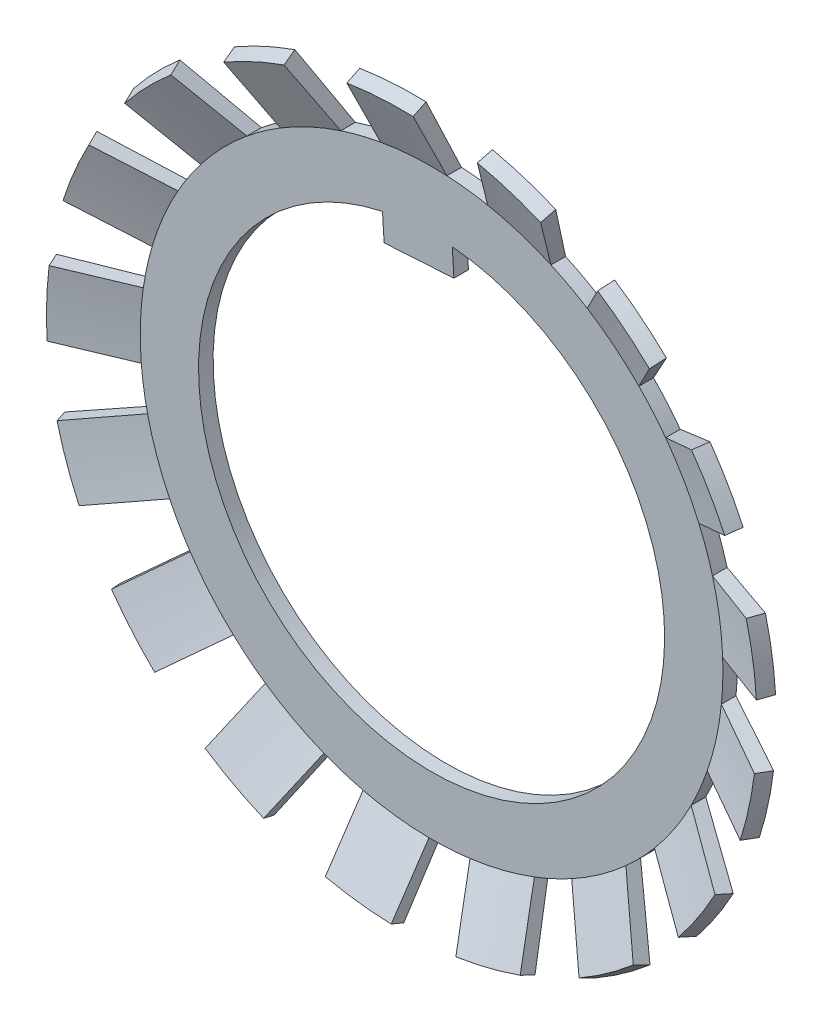
from build123d import *

# Parameters (mm, degrees)
SKETCH2_OUTSIDE_W        = 81.552
SKETCH2_OUTSIDE_H        = 81.552
SKETCH2_OUTSIDE_R        = 20
CUT_EXTRUDE_DEPTH        = 4.810952862
PATTERN_CIRCULAR_4_COUNT = 17
EXTRUDE_1_DEPTH          = 1.25


with BuildPart() as part:
    # Sketch1 → Base-Extrude (revolve)
    with BuildSketch(Plane.YZ):
        Polygon((0, -3.810952863), (-25, -3.810952863), (-31, -1.142110693), (-30.491981137, 0), (-25, -2.560952863), (0, -2.560952863), align=None)
    revolve(axis=Axis((0, 0, 5.823648763), (0, 0, -1)))

    # Sketch2 outside → Cut-Extrude (cut, through all)
    with BuildSketch(Plane(origin=(-2.40435344, 1.003568156, -3.810952862), x_dir=(-1, 0, 0), z_dir=(0, 0, -1))):
        with Locations((-2.404, -1.004)):
            Rectangle(SKETCH2_OUTSIDE_W, SKETCH2_OUTSIDE_H)
        with BuildLine():
            Line((-22.488842625, 13.883113616), (-27.712443889, 16.898961212))
            ThreePointArc((-27.712443889, 16.898961212), (-29.251140957, 14.496431844), (-30.562443889, 11.96261641))
            Line((-30.562443889, 11.96261641), (-25.338842625, 8.946768814))
            ThreePointArc((-25.338842625, 8.946768814), (19.246281655, -13.503568156), (-22.488842625, 13.883113616))
        make_face(mode=Mode.SUBTRACT)
        with Locations((-2.40435344, -1.003568156)):
            Circle(SKETCH2_OUTSIDE_R)
    extrude(amount=-CUT_EXTRUDE_DEPTH, mode=Mode.SUBTRACT)


with BuildPart() as pattern_circular_4_1:
    # 阵列(圆周)4: pattern copy
    add(part.part.rotate(Axis((0, 0, 0), (0, 0, 1)), 1 * 360 / PATTERN_CIRCULAR_4_COUNT))


with BuildPart() as pattern_circular_4_2:
    # 阵列(圆周)4: pattern copy
    add(part.part.rotate(Axis((0, 0, 0), (0, 0, 1)), 2 * 360 / PATTERN_CIRCULAR_4_COUNT))


with BuildPart() as pattern_circular_4_3:
    # 阵列(圆周)4: pattern copy
    add(part.part.rotate(Axis((0, 0, 0), (0, 0, 1)), 3 * 360 / PATTERN_CIRCULAR_4_COUNT))


with BuildPart() as pattern_circular_4_4:
    # 阵列(圆周)4: pattern copy
    add(part.part.rotate(Axis((0, 0, 0), (0, 0, 1)), 4 * 360 / PATTERN_CIRCULAR_4_COUNT))


with BuildPart() as pattern_circular_4_5:
    # 阵列(圆周)4: pattern copy
    add(part.part.rotate(Axis((0, 0, 0), (0, 0, 1)), 5 * 360 / PATTERN_CIRCULAR_4_COUNT))


with BuildPart() as pattern_circular_4_6:
    # 阵列(圆周)4: pattern copy
    add(part.part.rotate(Axis((0, 0, 0), (0, 0, 1)), 6 * 360 / PATTERN_CIRCULAR_4_COUNT))


with BuildPart() as pattern_circular_4_7:
    # 阵列(圆周)4: pattern copy
    add(part.part.rotate(Axis((0, 0, 0), (0, 0, 1)), 7 * 360 / PATTERN_CIRCULAR_4_COUNT))


with BuildPart() as pattern_circular_4_8:
    # 阵列(圆周)4: pattern copy
    add(part.part.rotate(Axis((0, 0, 0), (0, 0, 1)), 8 * 360 / PATTERN_CIRCULAR_4_COUNT))


with BuildPart() as pattern_circular_4_9:
    # 阵列(圆周)4: pattern copy
    add(part.part.rotate(Axis((0, 0, 0), (0, 0, 1)), 9 * 360 / PATTERN_CIRCULAR_4_COUNT))


with BuildPart() as pattern_circular_4_10:
    # 阵列(圆周)4: pattern copy
    add(part.part.rotate(Axis((0, 0, 0), (0, 0, 1)), 10 * 360 / PATTERN_CIRCULAR_4_COUNT))


with BuildPart() as pattern_circular_4_11:
    # 阵列(圆周)4: pattern copy
    add(part.part.rotate(Axis((0, 0, 0), (0, 0, 1)), 11 * 360 / PATTERN_CIRCULAR_4_COUNT))


with BuildPart() as pattern_circular_4_12:
    # 阵列(圆周)4: pattern copy
    add(part.part.rotate(Axis((0, 0, 0), (0, 0, 1)), 12 * 360 / PATTERN_CIRCULAR_4_COUNT))


with BuildPart() as pattern_circular_4_13:
    # 阵列(圆周)4: pattern copy
    add(part.part.rotate(Axis((0, 0, 0), (0, 0, 1)), 13 * 360 / PATTERN_CIRCULAR_4_COUNT))


with BuildPart() as pattern_circular_4_14:
    # 阵列(圆周)4: pattern copy
    add(part.part.rotate(Axis((0, 0, 0), (0, 0, 1)), 14 * 360 / PATTERN_CIRCULAR_4_COUNT))


with BuildPart() as pattern_circular_4_15:
    # 阵列(圆周)4: pattern copy
    add(part.part.rotate(Axis((0, 0, 0), (0, 0, 1)), 15 * 360 / PATTERN_CIRCULAR_4_COUNT))


with BuildPart() as pattern_circular_4_16:
    # 阵列(圆周)4: pattern copy
    add(part.part.rotate(Axis((0, 0, 0), (0, 0, 1)), 16 * 360 / PATTERN_CIRCULAR_4_COUNT))


with BuildPart() as part_1:
    add(part.part)

    add(pattern_circular_4_1.part)  # 凸台-拉伸1 merges 阵列(圆周)4_1

    add(pattern_circular_4_2.part)  # 凸台-拉伸1 merges 阵列(圆周)4_2

    add(pattern_circular_4_3.part)  # 凸台-拉伸1 merges 阵列(圆周)4_3

    add(pattern_circular_4_4.part)  # 凸台-拉伸1 merges 阵列(圆周)4_4

    add(pattern_circular_4_5.part)  # 凸台-拉伸1 merges 阵列(圆周)4_5

    add(pattern_circular_4_6.part)  # 凸台-拉伸1 merges 阵列(圆周)4_6

    add(pattern_circular_4_7.part)  # 凸台-拉伸1 merges 阵列(圆周)4_7

    add(pattern_circular_4_8.part)  # 凸台-拉伸1 merges 阵列(圆周)4_8

    add(pattern_circular_4_9.part)  # 凸台-拉伸1 merges 阵列(圆周)4_9

    add(pattern_circular_4_10.part)  # 凸台-拉伸1 merges 阵列(圆周)4_10

    add(pattern_circular_4_11.part)  # 凸台-拉伸1 merges 阵列(圆周)4_11

    add(pattern_circular_4_12.part)  # 凸台-拉伸1 merges 阵列(圆周)4_12

    add(pattern_circular_4_13.part)  # 凸台-拉伸1 merges 阵列(圆周)4_13

    add(pattern_circular_4_14.part)  # 凸台-拉伸1 merges 阵列(圆周)4_14

    add(pattern_circular_4_15.part)  # 凸台-拉伸1 merges 阵列(圆周)4_15

    add(pattern_circular_4_16.part)  # 凸台-拉伸1 merges 阵列(圆周)4_16
    # 草图2 → 凸台-拉伸1 (add)
    with BuildSketch(Plane.XY.offset(-2.560952863)):
        with BuildLine():
            Line((1.916994129, 17.651490971), (1.777021869, 19.920898405))
            ThreePointArc((1.777021869, 19.920898405), (-1.231218123, 19.962066575), (-4.211598103, 19.551532969))
            Line((-4.211598103, 19.551532969), (-4.071625844, 17.282125534))
            Line((-4.071625844, 17.282125534), (1.916994129, 17.651490971))
        make_face()
    extrude(amount=-EXTRUDE_1_DEPTH)


solid = part_1.part
